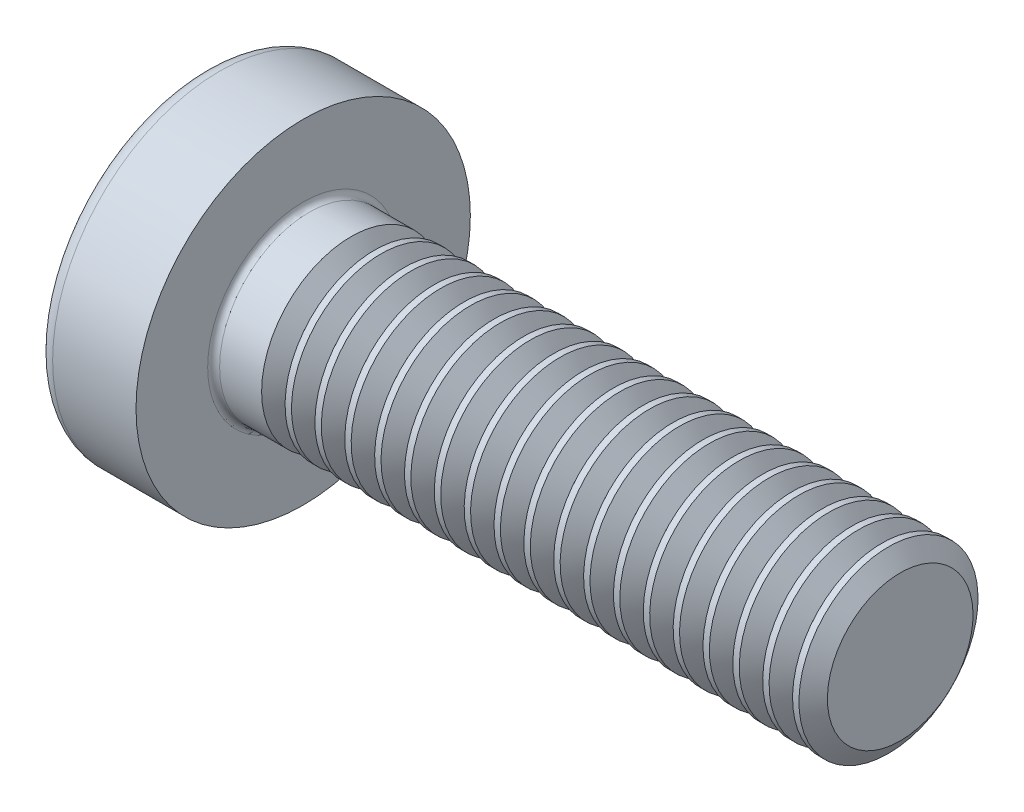
from build123d import *

# Parameters (mm, degrees)
FILLET1_R       = 0.1
SKETCH3_W       = 0.74
SKETCH3_H       = 2.8
SKETCH4_W       = 0.74
SKETCH4_H       = 1.054964664
RECPAT_COUNT    = 2
RECPAT_ANGLE    = 90
THDSCHPAT_COUNT = 19
THDSCHPAT_PITCH = 0.5


with BuildPart() as part:
    # BodySke → Base-Revolve (revolve)
    with BuildSketch(Plane.XY):
        with BuildLine():
            Line((2.4, 1.5), (2.4, 2.8))
            Line((2.4, 2.8), (1.003501533, 2.8))
            ThreePointArc((1.003501533, 2.8), (0.873295971, 2.76653015), (0.775371599, 2.674418605))
            ThreePointArc((0.775371599, 2.674418605), (0.197753546, 1.392274756), (0, 0))
            Line((0, 0), (12.4, 0))
            Line((12.4, 0), (12.4, 1.5))
            Line((12.4, 1.5), (2.4, 1.5))
        make_face()
    revolve(axis=Axis((-25.4, 0, 0), (1, 0, 0)))

    # Fillet1
    fillet1_edges = [part.edges().sort_by_distance(p)[0] for p in [
        (2.4, -1.5, 0),
    ]]
    fillet(fillet1_edges, radius=FILLET1_R)

    # Sketch3 → Recess section 0
    with BuildSketch(Plane(origin=(0, 0, 0), x_dir=(0, 0, -1), z_dir=(1, 0, 0))):
        Rectangle(SKETCH3_W, SKETCH3_H)
    # Sketch4 → Recess section 1
    with BuildSketch(Plane(origin=(1.75, 0, 0), x_dir=(0, 0, -1), z_dir=(1, 0, 0))):
        Rectangle(SKETCH4_W, SKETCH4_H)
    recess = loft(mode=Mode.SUBTRACT)

    # RecPat: Recess ×2 about axis
    recpat_axis = Axis((0, 0, 0), (1, 0, 0))
    for i in range(1, RECPAT_COUNT):
        add(recess.rotate(recpat_axis, i * RECPAT_ANGLE / (RECPAT_COUNT - 1)), mode=Mode.SUBTRACT)

    # RecCorSke → RecessCore (revolve, cut)
    with BuildSketch(Plane.XY):
        Polygon((0, 0), (0, 0.678371921), (1.75, 0.556), (1.930655351, 0), align=None)
    revolve(axis=Axis((-3.175, 0, 0), (1, 0, 0)), mode=Mode.SUBTRACT)

    # ThdSchSke → ThreadSchematic (revolve, cut)
    with BuildSketch(Plane.XY):
        Polygon((3.4, -1.2195), (3.203591786, -1.5), (3.203591786, -1.875), (3.596408214, -1.875), (3.596408214, -1.5), align=None)
    threadschematic = revolve(axis=Axis((-3.175, 0, 0), (1, 0, 0)), mode=Mode.SUBTRACT)

    # ThdSchPat: ThreadSchematic ×19
    with Locations(*[(i * THDSCHPAT_PITCH, 0, 0) for i in range(1, THDSCHPAT_COUNT)]):
        add(threadschematic, mode=Mode.SUBTRACT)


solid = part.part
